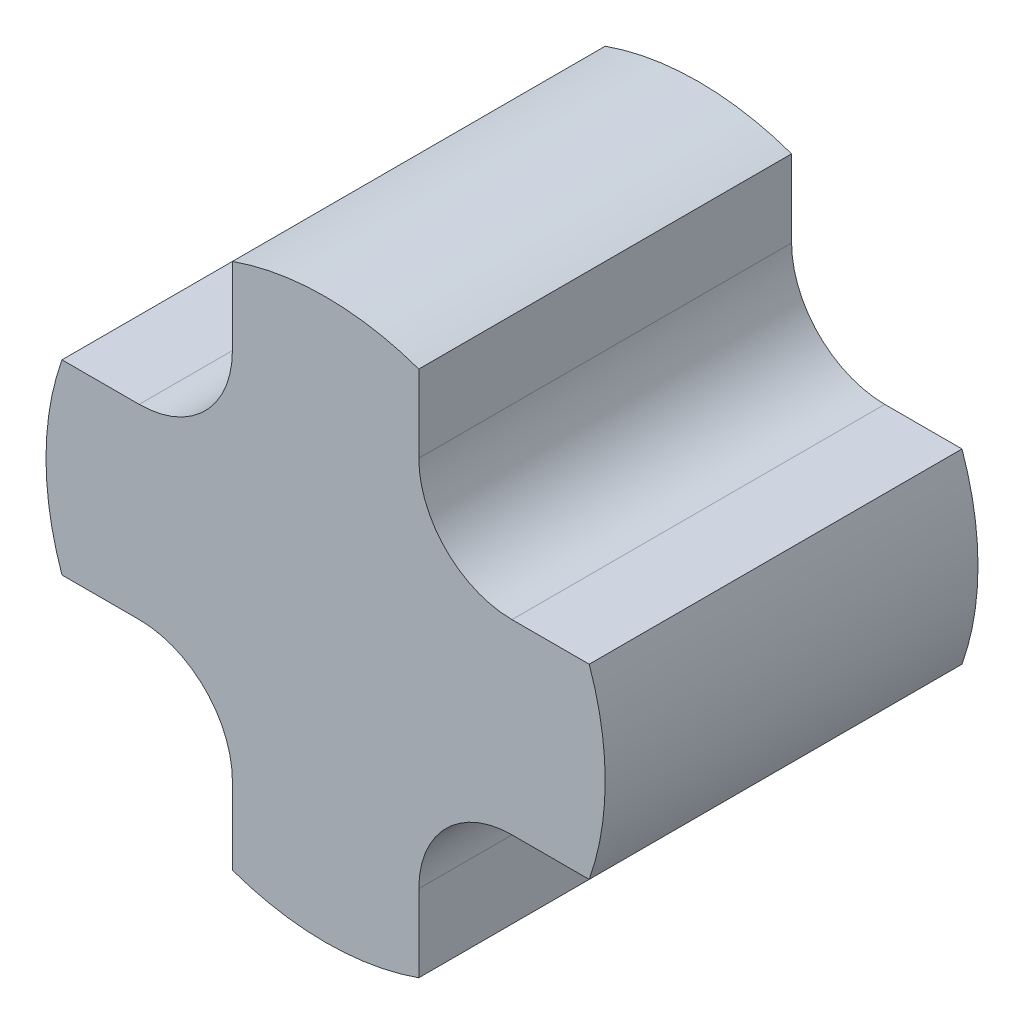
from build123d import *

# Parameters (mm, degrees)
BOSS_EXTRUDE1_DEPTH = 200
CIRPATTERN1_COUNT   = 4
FILLET1_R           = 50


with BuildPart() as part:
    # Sketch1 → Boss-Extrude1 (new body)
    with BuildSketch(Plane(origin=(0, 0, 0), x_dir=(0, 1, 0), z_dir=(0, 0, 1))):
        with BuildLine():
            Line((-50, 141.421356237), (-50, 0))
            Line((-50, 0), (50, 0))
            Line((50, 0), (50, 141.421356237))
            ThreePointArc((50, 141.421356237), (0, 150), (-50, 141.421356237))
        make_face()
    extrude(amount=BOSS_EXTRUDE1_DEPTH)


with BuildPart() as cirpattern1_1:
    # CirPattern1: pattern copy
    add(part.part.rotate(Axis((0, 0, -10), (0, 0, 1)), 1 * 360 / CIRPATTERN1_COUNT))


with BuildPart() as cirpattern1_2:
    # CirPattern1: pattern copy
    add(part.part.rotate(Axis((0, 0, -10), (0, 0, 1)), 2 * 360 / CIRPATTERN1_COUNT))


with BuildPart() as cirpattern1_3:
    # CirPattern1: pattern copy
    add(part.part.rotate(Axis((0, 0, -10), (0, 0, 1)), 3 * 360 / CIRPATTERN1_COUNT))


with BuildPart() as part_1:
    add(part.part)

    # Combine1: union CirPattern1_1, CirPattern1_2, CirPattern1_3
    add(cirpattern1_1.part)
    add(cirpattern1_2.part)
    add(cirpattern1_3.part)

    # Fillet1
    fillet1_edges = [part_1.edges().sort_by_distance(p)[0] for p in [
        (50, 50, 100),
        (50, -50, 100),
        (-50, 50, 100),
        (-50, -50, 100),
    ]]
    fillet(fillet1_edges, radius=FILLET1_R)


solid = part_1.part
